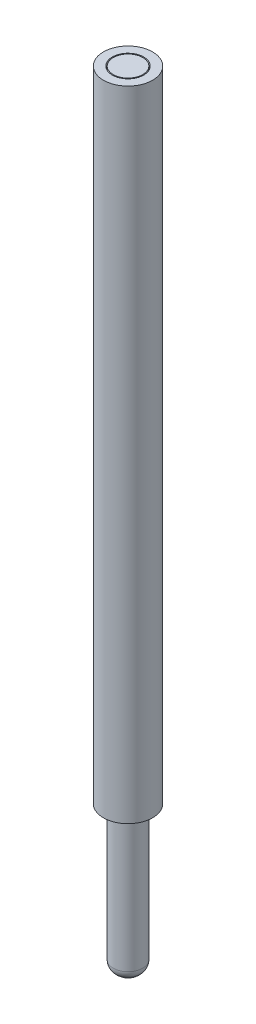
from build123d import *

# Parameters (mm, degrees)
SKETCH1_W = 0.45
SKETCH1_H = 32.5
FILLET1_R = 0.5


with BuildPart() as part:
    # Sketch1 → Revolve1 (revolve)
    with BuildSketch(Plane.XY):
        with BuildLine():
            Line((0, 0), (0, 40))
            Line((0, 40), (0.75, 40))
            Line((0.75, 40), (0.75, 0.5))
            ThreePointArc((0.75, 0.5), (0.450693909, 0.136459136), (0, 0))
        make_face()
        with Locations((1.025, 23.75)):
            Rectangle(SKETCH1_W, SKETCH1_H)
    revolve(axis=Axis((0, 0, 0), (0, 1, 0)))

    # Fillet1
    fillet1_edges = [part.edges().sort_by_distance(p)[0] for p in [
        (-0.75, 0.5, 0),
    ]]
    fillet(fillet1_edges, radius=FILLET1_R)


solid = part.part
